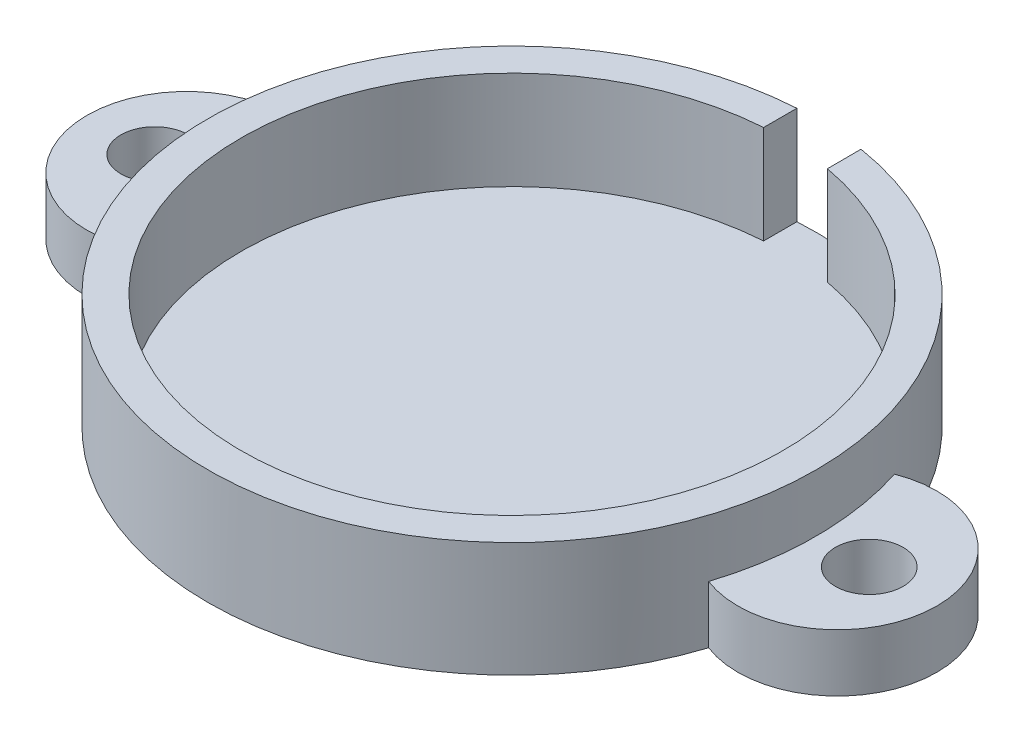
from build123d import *

# Parameters (mm, degrees)
SKETCH1_R           = 58.166
BOSS_EXTRUDE1_DEPTH = 21.971
SKETCH3_R           = 51.816
CUT_EXTRUDE2_DEPTH  = 18.796
CUT_EXTRUDE7_DEPTH  = 18.796
SKETCH7_R           = 6.477
BOSS_EXTRUDE3_DEPTH = 10.9855


with BuildPart() as part:
    # Sketch1 → Boss-Extrude1 (new body)
    with BuildSketch(Plane(origin=(0, 0, 0), x_dir=(1, 0, 0), z_dir=(0, 1, 0))):
        Circle(SKETCH1_R)
    extrude(amount=BOSS_EXTRUDE1_DEPTH)

    # Sketch3 → Cut-Extrude2 (cut)
    with BuildSketch(Plane(origin=(0, 21.971, 0), x_dir=(1, 0, 0), z_dir=(0, 1, 0))):
        Circle(SKETCH3_R)
    extrude(amount=-CUT_EXTRUDE2_DEPTH, mode=Mode.SUBTRACT)

    # Sketch6 → Cut-Extrude7 (cut)
    with BuildSketch(Plane(origin=(0, 21.971, 0), x_dir=(1, 0, 0), z_dir=(0, 1, 0))):
        with BuildLine():
            Line((9.363048829, 50.963037318), (9.340756891, 57.411094892))
            ThreePointArc((9.340756891, 57.411094892), (2.903170649, 58.093503563), (-3.57037671, 58.056317194))
            Line((-3.57037671, 58.056317194), (-3.57037671, 51.692845406))
            ThreePointArc((-3.57037671, 51.692845406), (2.919232353, 51.733702153), (9.363048829, 50.963037318))
        make_face()
    extrude(amount=-CUT_EXTRUDE7_DEPTH, mode=Mode.SUBTRACT)

    # Sketch7 → Boss-Extrude3 (add)
    with BuildSketch(Plane.XZ):
        with BuildLine():
            ThreePointArc((55.382885714, -17.776938037), (81.28, 0), (55.382885714, 17.776938037))
            ThreePointArc((55.382885714, 17.776938037), (58.166, 0), (55.382885714, -17.776938037))
        make_face()
        with Locations((68.326, 0)):
            Circle(SKETCH7_R, mode=Mode.SUBTRACT)
        with BuildLine():
            ThreePointArc((-55.382885714, 17.776938037), (-81.28, 0), (-55.382885714, -17.776938037))
            ThreePointArc((-55.382885714, -17.776938037), (-58.166, 0), (-55.382885714, 17.776938037))
        make_face()
        with Locations((-68.323824172, 0)):
            Circle(SKETCH7_R, mode=Mode.SUBTRACT)
    extrude(amount=-BOSS_EXTRUDE3_DEPTH)


solid = part.part
